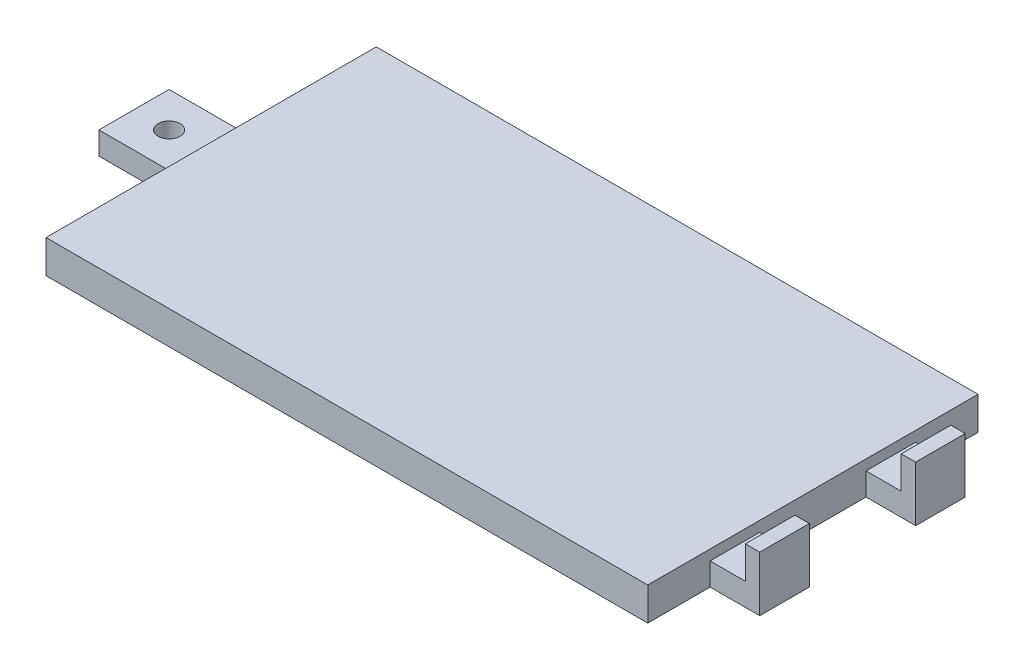
from build123d import *

# Parameters (mm, degrees)
SKETCH2_W               = 54.61
SKETCH2_H               = 29.97
SKETCH2_W_2             = 7
SKETCH2_H_2             = 6.37
SKETCH2_W_3             = 4.5
SKETCH2_H_3             = 4.5
BOSS_EXTRUDE4_DEPTH     = 3
SKETCH3_W               = 7
SKETCH3_H               = 6.37
BOSS_EXTRUDE5_DEPTH     = 3
SKETCH4_W               = 4.5
SKETCH4_H               = 4.5
BOSS_EXTRUDE6_DEPTH     = 2
SKETCH6_W               = 3.19390973
SKETCH6_H               = 2.94
CUT_EXTRUDE1_DEPTH      = 6.66
CUT_EXTRUDE1_DEPTH_BACK = 25.31
CUT_EXTRUDE3_REACH      = 20.17
SKETCH10_R              = 1
CUT_EXTRUDE4_DEPTH      = 5
SKETCH12_R              = 1.25
CUT_EXTRUDE5_DEPTH      = 0.5


with BuildPart() as part:
    # Sketch2 → Boss-Extrude4 (new body)
    with BuildSketch(Plane(origin=(0, 0, 0), x_dir=(1, 0, 0), z_dir=(0, 1, 0))):
        with Locations((-10.436162564, 12.528789446)):
            Rectangle(SKETCH2_W, SKETCH2_H)
        with Locations((-41.241162564, 12.528789446)):
            Rectangle(SKETCH2_W_2, SKETCH2_H_2)
        with Locations((19.118837436, 5.453789446)):
            Rectangle(SKETCH2_W_3, SKETCH2_H_3)
        with Locations((19.118837436, 19.603789446)):
            Rectangle(SKETCH2_W_3, SKETCH2_H_3)
    extrude(amount=BOSS_EXTRUDE4_DEPTH)

    # Sketch3 → Boss-Extrude5 (add)
    with BuildSketch(Plane(origin=(0, 3, 0), x_dir=(1, 0, 0), z_dir=(0, 1, 0))):
        with Locations((-41.241162564, 12.528789446)):
            Rectangle(SKETCH3_W, SKETCH3_H)
    extrude(amount=BOSS_EXTRUDE5_DEPTH)

    # Sketch4 → Boss-Extrude6 (add)
    with BuildSketch(Plane(origin=(0, 3, 0), x_dir=(1, 0, 0), z_dir=(0, 1, 0))):
        with Locations((19.118837436, 19.603789446)):
            Rectangle(SKETCH4_W, SKETCH4_H)
        with Locations((19.118837436, 5.453789446)):
            Rectangle(SKETCH4_W, SKETCH4_H)
    extrude(amount=BOSS_EXTRUDE6_DEPTH)

    # Sketch6 → Cut-Extrude1 (cut, two sides)
    with BuildSketch(Plane.XY.offset(-3.203789446)) as cut_extrude1_sk:
        with Locations((18.465792301, 3.53)):
            Rectangle(SKETCH6_W, SKETCH6_H)
    extrude(amount=CUT_EXTRUDE1_DEPTH, mode=Mode.SUBTRACT)
    extrude(cut_extrude1_sk.sketch, amount=-CUT_EXTRUDE1_DEPTH_BACK, mode=Mode.SUBTRACT)

    # Sketch8 → Cut-Extrude3 (cut, up to next)
    with BuildSketch(Plane.XY.offset(-9.343789446), mode=Mode.PRIVATE) as cut_extrude3_sk1:
        Polygon((-37.741162564, 6), (-42.018009261, 6), (-42.018009261, 6.012510793), (-43.247603098, 6.012510793), (-43.247603098, 6.015261621), (-44.781895645, 6.015261621), (-44.781895645, 2.058576766), (-37.741162564, 2.058576766), align=None)
    cut_extrude3_tool1 = extrude(cut_extrude3_sk1.sketch, amount=-CUT_EXTRUDE3_REACH, mode=Mode.PRIVATE) & part.part
    add(cut_extrude3_tool1.solids().sort_by_distance((-41.264608, 4.03205, -9.343789))[0], mode=Mode.SUBTRACT)

    # Sketch10 → Cut-Extrude4 (cut)
    with BuildSketch(Plane.XZ):
        with Locations((-41.551162564, -12.528789446)):
            Circle(SKETCH10_R)
    extrude(amount=-CUT_EXTRUDE4_DEPTH, mode=Mode.SUBTRACT)

    # Sketch12 → Cut-Extrude5 (cut)
    with BuildSketch(Plane.XZ):
        with Locations((-41.551162564, -12.528789446)):
            Circle(SKETCH12_R)
    extrude(amount=-CUT_EXTRUDE5_DEPTH, mode=Mode.SUBTRACT)


solid = part.part
